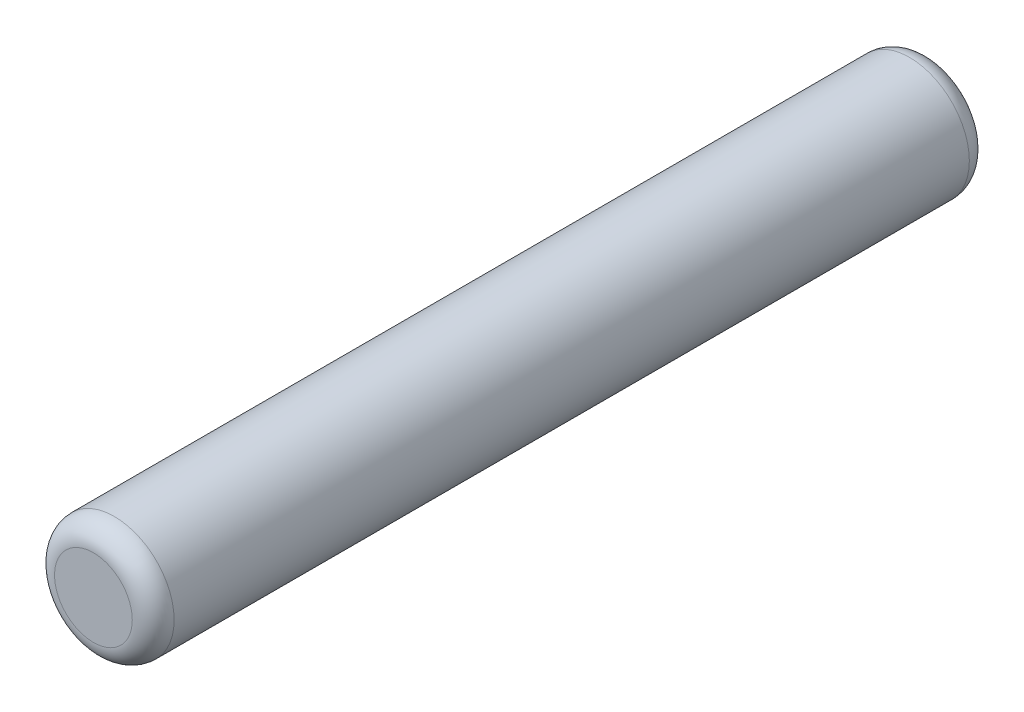
from build123d import *

# Parameters (mm, degrees)
SKETCH1_R           = 1
BOSS_EXTRUDE1_DEPTH = 7
FILLET1_R           = 0.35


with BuildPart() as part:
    # Sketch1 → Boss-Extrude1 (new body, symmetric)
    with BuildSketch(Plane.XY):
        Circle(SKETCH1_R)
    extrude(amount=BOSS_EXTRUDE1_DEPTH, both=True)

    # Fillet1
    fillet1_edges = [part.edges().sort_by_distance(p)[0] for p in [
        (-1, 0, -7),
        (-1, 0, 7),
    ]]
    fillet(fillet1_edges, radius=FILLET1_R)


solid = part.part
